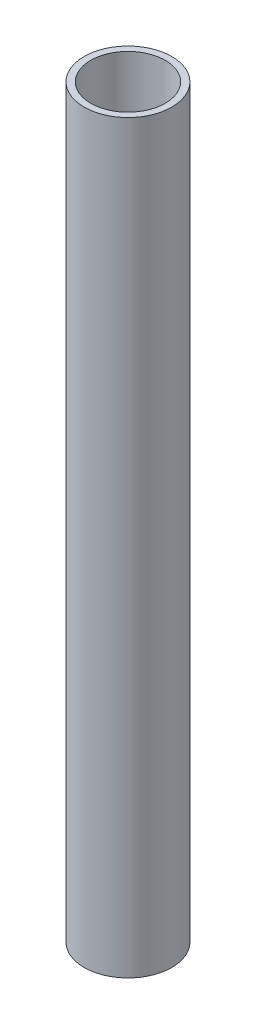
from build123d import *

# Parameters (mm, degrees)
SKETCH1_R           = 12.7
SKETCH1_R_2         = 10.795
BOSS_EXTRUDE1_DEPTH = 215.9


with BuildPart() as part:
    # Sketch1 → Boss-Extrude1 (new body)
    with BuildSketch(Plane(origin=(0, 0, 0), x_dir=(1, 0, 0), z_dir=(0, 1, 0))):
        Circle(SKETCH1_R)
        Circle(SKETCH1_R_2, mode=Mode.SUBTRACT)
    extrude(amount=BOSS_EXTRUDE1_DEPTH)


solid = part.part
